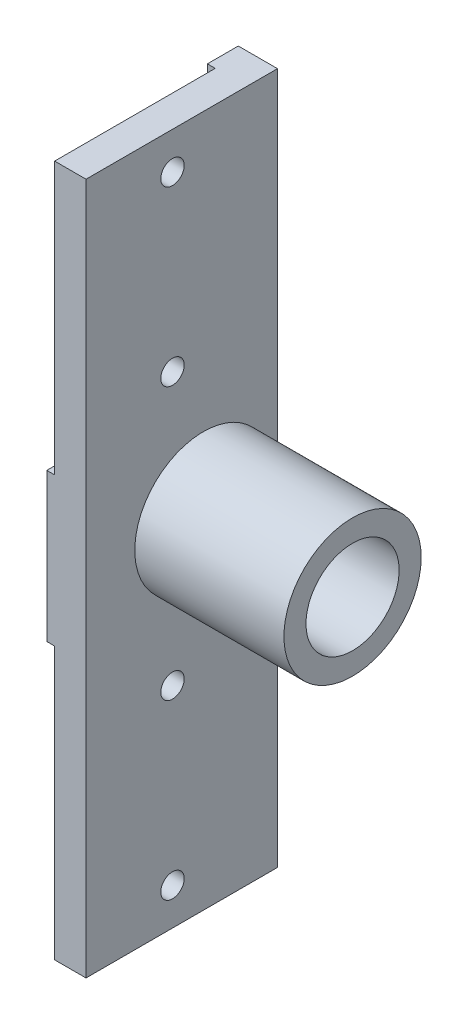
from build123d import *

# Parameters (mm, degrees)
SKETCH1_W                       = 31
SKETCH1_H                       = 56
BOSS_EXTRUDE1_DEPTH             = 6.35
SKETCH2_R                       = 11.1125
BOSS_EXTRUDE2_DEPTH             = 24.15253802
SKETCH3_R                       = 7.54126
CUT_EXTRUDE1_DEPTH              = 31.50253802
SKETCH4_W                       = 26
SKETCH4_H                       = 44
CUT_EXTRUDE2_DEPTH              = 1.27
FILLET1_R                       = 3.175
FILLET1_OF_MIRROR2_R            = 3.175
F_10_24_TAPPED_HOLE1_AT_2_COUNT = 2
F_10_24_TAPPED_HOLE1_AT_2_PITCH = 28


with BuildPart() as part:
    # Sketch1 → Boss-Extrude1 (new body)
    with BuildSketch(Plane(origin=(0, 0, 0), x_dir=(0, 0, -1), z_dir=(1, 0, 0))):
        with Locations((-3.5, 28)):
            Rectangle(SKETCH1_W, SKETCH1_H)
    boss_extrude1 = extrude(amount=BOSS_EXTRUDE1_DEPTH)

    # Mirror1: Boss-Extrude1 across plane
    add(boss_extrude1.mirror(Plane.ZX))

    # Sketch2 → Boss-Extrude2 (add)
    with BuildSketch(Plane(origin=(6.35, 0, 0), x_dir=(0, 0, -1), z_dir=(1, 0, 0))):
        Circle(SKETCH2_R)
    extrude(amount=BOSS_EXTRUDE2_DEPTH)

    # Sketch3 → Cut-Extrude1 (cut, through all)
    with BuildSketch(Plane.ZY):
        Circle(SKETCH3_R)
    extrude(amount=-CUT_EXTRUDE1_DEPTH, mode=Mode.SUBTRACT)

    # Sketch4 → Cut-Extrude2 (cut)
    with BuildSketch(Plane.ZY):
        with Locations((6, 34)):
            Rectangle(SKETCH4_W, SKETCH4_H)
    cut_extrude2 = extrude(amount=-CUT_EXTRUDE2_DEPTH, mode=Mode.SUBTRACT)

    # Fillet1
    fillet1_edges = [part.edges().sort_by_distance(p)[0] for p in [
        (0.635, 12, -7),
    ]]
    fillet(fillet1_edges, radius=FILLET1_R)

    # Mirror2: Cut-Extrude2 across plane
    add(cut_extrude2.mirror(Plane.ZX), mode=Mode.SUBTRACT)

    # Fillet1 of Mirror2
    fillet1_of_mirror2_edges = [part.edges().sort_by_distance(p)[0] for p in [
        (0.635, -12, -7),
    ]]
    fillet(fillet1_of_mirror2_edges, radius=FILLET1_OF_MIRROR2_R)

    # Sketch5 → #10-24 Tapped Hole1 (revolve, cut)
    with BuildSketch(Plane(origin=(1.27, 50, 5), x_dir=(0, 0, 1), z_dir=(0, 1, 0))):
        Polygon((0, 0), (0, 16.090824014), (1.89865, 14.95), (1.89865, 0), align=None)
    f_10_24_tapped_hole1 = revolve(axis=Axis((-5.08, 50, 5), (1, 0, 0)), mode=Mode.SUBTRACT)

    # #10-24 Tapped Hole1 at 2: #10-24 Tapped Hole1 ×2
    with Locations(*[(0, -i * F_10_24_TAPPED_HOLE1_AT_2_PITCH, 0) for i in range(1, F_10_24_TAPPED_HOLE1_AT_2_COUNT)]):
        add(f_10_24_tapped_hole1, mode=Mode.SUBTRACT)

    # Mirror3: #10-24 Tapped Hole1 across plane
    add(f_10_24_tapped_hole1.mirror(Plane.ZX), mode=Mode.SUBTRACT)

    # Mirror3 copy 1 sketch → Mirror3 copy 1 (revolve, cut)
    with BuildSketch(Plane(origin=(1.27, -22, 5), x_dir=(0, 0, 1), z_dir=(0, -1, 0))):
        Polygon((0, 0), (0, -16.090824014), (1.89865, -14.95), (1.89865, 0), align=None)
    revolve(axis=Axis((-5.08, -22, 5), (-1, 0, 0)), mode=Mode.SUBTRACT)


solid = part.part
